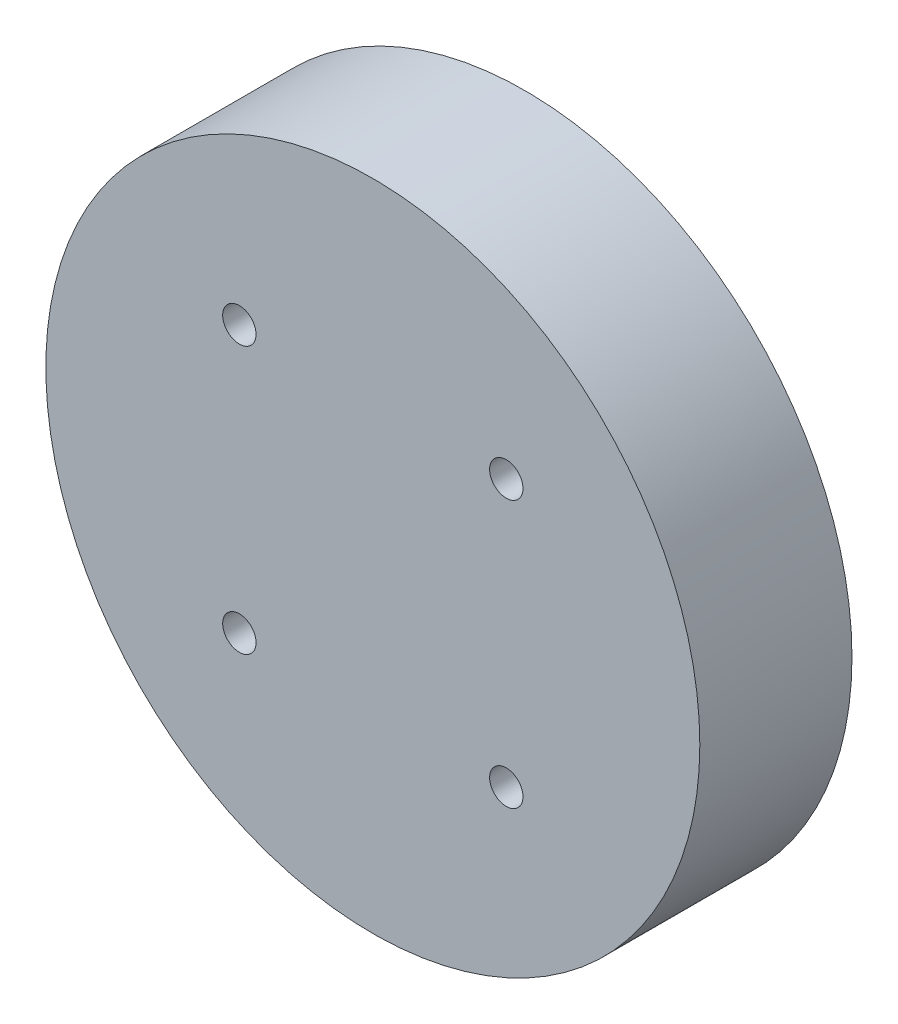
from build123d import *

# Parameters (mm, degrees)
SKETCH_1_R          = 24.5
EXTRUDE_1_DEPTH     = 11.4
SKETCH_2_R          = 1.25
CUT_EXTRUDE_1_DEPTH = 8


with BuildPart() as part:
    # 草图1 → 凸台-拉伸1 (new body)
    with BuildSketch(Plane.XY):
        Circle(SKETCH_1_R)
    extrude(amount=EXTRUDE_1_DEPTH)

    # 草图2 → 切除-拉伸1 (cut)
    with BuildSketch(Plane.XY.offset(11.4)):
        with Locations((-10, 10)):
            Circle(SKETCH_2_R)
        with Locations((10, 10)):
            Circle(SKETCH_2_R)
        with Locations((-10, -10)):
            Circle(SKETCH_2_R)
        with Locations((10, -10)):
            Circle(SKETCH_2_R)
    extrude(amount=-CUT_EXTRUDE_1_DEPTH, mode=Mode.SUBTRACT)


solid = part.part
